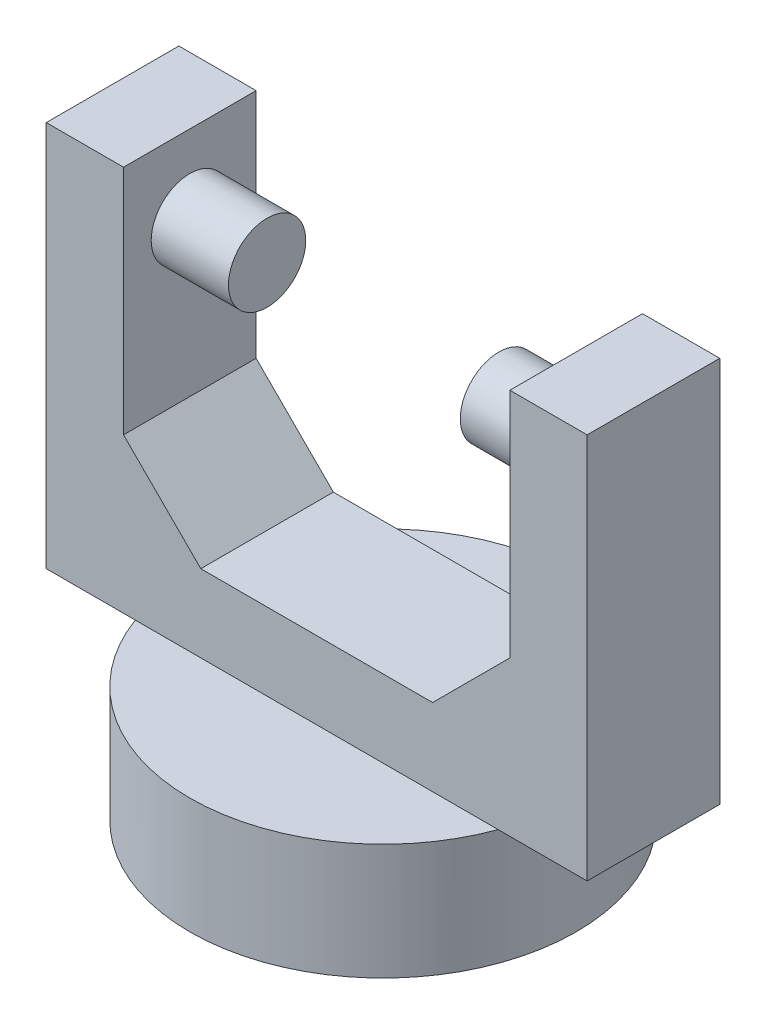
from build123d import *

# Parameters (mm, degrees)
SKETCH1_R           = 12.5
BOSS_EXTRUDE1_DEPTH = 7.5
SKETCH2_W           = 35
SKETCH2_H           = 8.580767914
BOSS_EXTRUDE2_DEPTH = 25
SKETCH3_W           = 25
SKETCH3_H           = 8.580767914
CUT_EXTRUDE1_DEPTH  = 20
SKETCH4_R           = 2.5
BOSS_EXTRUDE3_DEPTH = 5
SKETCH5_R           = 2.5
BOSS_EXTRUDE4_DEPTH = 5
CHAMFER1_SIZE       = 5
CHAMFER2_SIZE       = 5


with BuildPart() as part:
    # Sketch1 → Boss-Extrude1 (new body)
    with BuildSketch(Plane(origin=(0, 0, 0), x_dir=(1, 0, 0), z_dir=(0, 1, 0))):
        Circle(SKETCH1_R)
    extrude(amount=BOSS_EXTRUDE1_DEPTH)

    # Sketch2 → Boss-Extrude2 (add)
    with BuildSketch(Plane(origin=(0, 7.5, 0), x_dir=(1, 0, 0), z_dir=(0, 1, 0))):
        Rectangle(SKETCH2_W, SKETCH2_H)
    extrude(amount=BOSS_EXTRUDE2_DEPTH)

    # Sketch3 → Cut-Extrude1 (cut)
    with BuildSketch(Plane(origin=(0, 32.5, 0), x_dir=(1, 0, 0), z_dir=(0, 1, 0))):
        Rectangle(SKETCH3_W, SKETCH3_H)
    extrude(amount=-CUT_EXTRUDE1_DEPTH, mode=Mode.SUBTRACT)

    # Sketch4 → Boss-Extrude3 (add)
    with BuildSketch(Plane(origin=(-12.5, 0, 0), x_dir=(0, 0, -1), z_dir=(1, 0, 0))):
        with Locations((0, 27.5)):
            Circle(SKETCH4_R)
    extrude(amount=BOSS_EXTRUDE3_DEPTH)

    # Sketch5 → Boss-Extrude4 (add)
    with BuildSketch(Plane.ZY.offset(-12.5)):
        with Locations((0, 27.5)):
            Circle(SKETCH5_R)
    extrude(amount=BOSS_EXTRUDE4_DEPTH)

    # Chamfer1
    chamfer1_edges = [part.edges().sort_by_distance(p)[0] for p in [
        (-12.5, 12.5, 0),
    ]]
    chamfer(chamfer1_edges, length=CHAMFER1_SIZE)

    # Chamfer2
    chamfer2_edges = [part.edges().sort_by_distance(p)[0] for p in [
        (12.5, 12.5, 0),
    ]]
    chamfer(chamfer2_edges, length=CHAMFER2_SIZE)


solid = part.part
